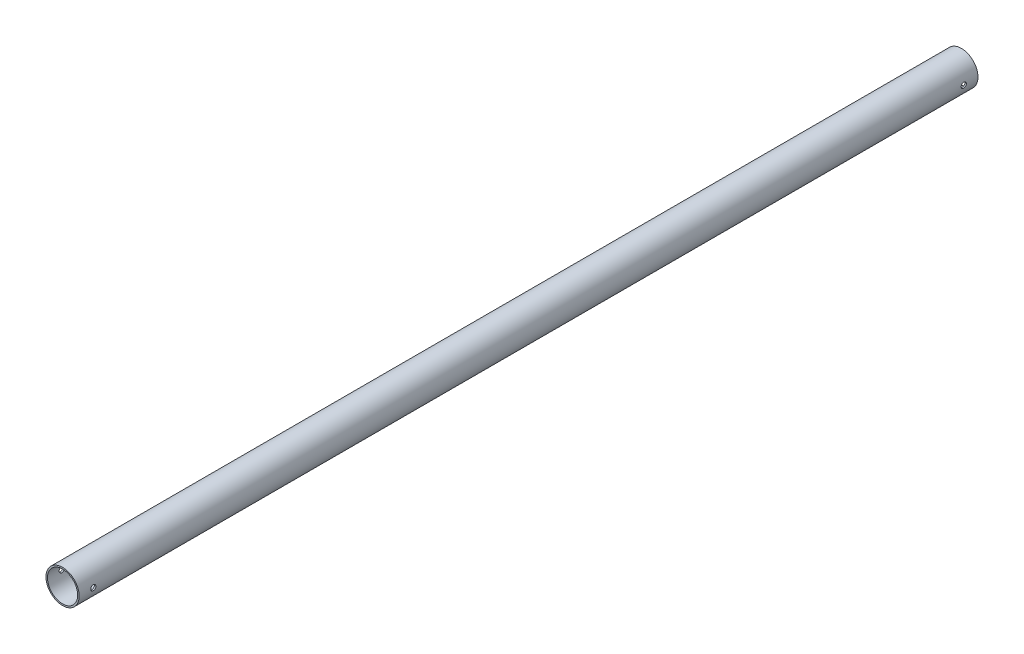
from build123d import *

# Parameters (mm, degrees)
SKETCH2_R                                  = 17.5
SKETCH2_R_2                                = 15.9125
BOSS_EXTRUDE1_DEPTH                        = 474
SKETCH5_W                                  = 2.75
SKETCH5_H                                  = 17.5
MIRROR1_AT_THE_SECOND_PLANE_COPY_1_SKETC_W = 2.75
MIRROR1_AT_THE_SECOND_PLANE_COPY_1_SKETC_H = 17.5


with BuildPart() as part:
    # Sketch2 → Boss-Extrude1 (new body, symmetric)
    with BuildSketch(Plane.XY):
        Circle(SKETCH2_R)
        Circle(SKETCH2_R_2, mode=Mode.SUBTRACT)
    extrude(amount=BOSS_EXTRUDE1_DEPTH, both=True)

    # Sketch5 → M5 Clearance Hole1 (revolve, cut)
    with BuildSketch(Plane(origin=(0, 0, -459), x_dir=(0, 0, 1), z_dir=(0, 1, 0))):
        with Locations((1.375, 8.75)):
            Rectangle(SKETCH5_W, SKETCH5_H)
    m5_clearance_hole1 = revolve(axis=Axis((-6.35, 0, -459), (1, 0, 0)), mode=Mode.SUBTRACT)

    # Mirror1: M5 Clearance Hole1 across plane
    add(m5_clearance_hole1.mirror(Plane.XY), mode=Mode.SUBTRACT)

    # Mirror1 at the second plane: M5 Clearance Hole1 across plane
    add(m5_clearance_hole1.mirror(Plane(origin=(0, 0, 0), x_dir=(0, 0, 1), z_dir=(1, 0, 0))), mode=Mode.SUBTRACT)

    # Mirror1 at the second plane copy 1 sketc → Mirror1 at the second plane copy 1 (revolve, cut)
    with BuildSketch(Plane(origin=(0, 0, 459), x_dir=(0, 0, -1), z_dir=(0, 1, 0))):
        with Locations((1.375, 8.75)):
            Rectangle(MIRROR1_AT_THE_SECOND_PLANE_COPY_1_SKETC_W, MIRROR1_AT_THE_SECOND_PLANE_COPY_1_SKETC_H)
    revolve(axis=Axis((6.35, 0, 459), (-1, 0, 0)), mode=Mode.SUBTRACT)


solid = part.part
